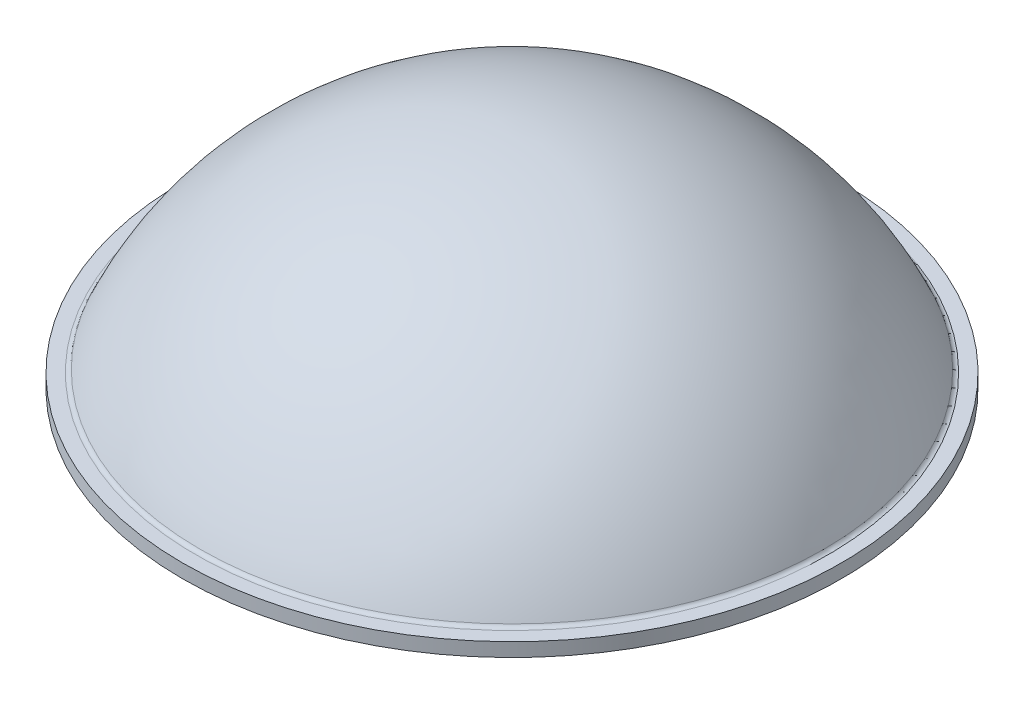
from build123d import *


with BuildPart() as part:
    # Sketch2 → Revolve1 (revolve)
    with BuildSketch(Plane(origin=(0, 0, 0), x_dir=(0, 0, -1), z_dir=(1, 0, 0))):
        with BuildLine():
            Line((-4.7625, 0), (-4.7625, 0.1984375))
            Line((-4.7625, 0.1984375), (-4.5640625, 0.1984375))
            ThreePointArc((-4.5640625, 0.1984375), (-4.527929162, 0.209178882), (-4.503531167, 0.237914456))
            ThreePointArc((-4.503531167, 0.237914456), (-2.688320315, 2.37584115), (0, 3.175))
            Line((0, 3.175), (0, 0))
            Line((0, 0), (-4.7625, 0))
        make_face()
    revolve(axis=Axis((0, 0, 0), (0, 1, 0)))


solid = part.part
